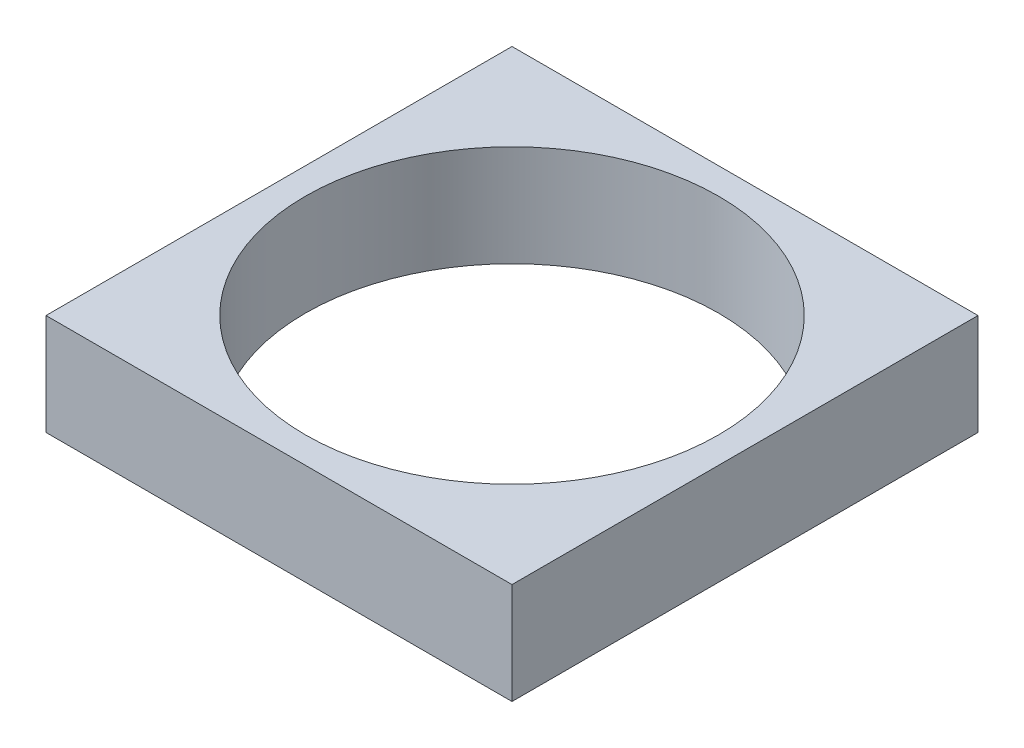
from build123d import *

# Parameters (mm, degrees)
SKETCH1_W           = 23
SKETCH1_H           = 23
SKETCH1_R           = 10.2
BOSS_EXTRUDE1_DEPTH = 2.5


with BuildPart() as part:
    # Sketch1 → Boss-Extrude1 (new body, symmetric)
    with BuildSketch(Plane(origin=(0, 0, 0), x_dir=(1, 0, 0), z_dir=(0, 1, 0))):
        Rectangle(SKETCH1_W, SKETCH1_H)
        Circle(SKETCH1_R, mode=Mode.SUBTRACT)
    extrude(amount=BOSS_EXTRUDE1_DEPTH, both=True)


solid = part.part
